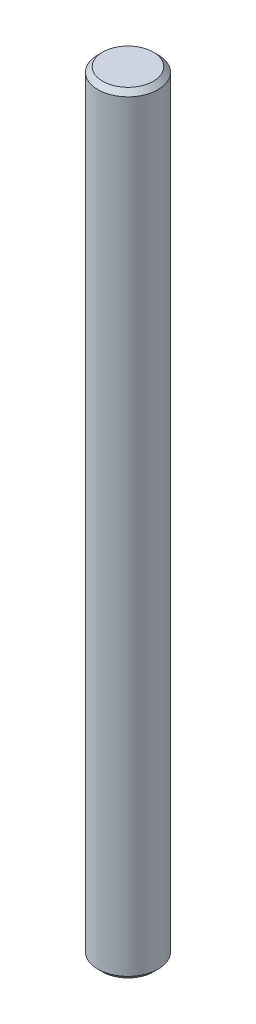
from build123d import *

# Parameters (mm, degrees)
SKETCH1_R      = 0.79375
EXTRUDE1_DEPTH = 10.16
CHAMFER1_SIZE  = 0.127


with BuildPart() as part:
    # Sketch1 → Extrude1 (new, symmetric)
    with BuildSketch(Plane(origin=(0, 0, 0), x_dir=(1, 0, 0), z_dir=(0, 1, 0))):
        with Locations(Location((0, 0, 0), (0, 0, 270))):
            Circle(SKETCH1_R)
    extrude(amount=EXTRUDE1_DEPTH, both=True)

    # Chamfer1
    chamfer1_edges = [part.edges().sort_by_distance(p)[0] for p in [
        (0, -10.16, -0.79375),
        (0, 10.16, -0.79375),
    ]]
    chamfer(chamfer1_edges, length=CHAMFER1_SIZE)


solid = part.part
